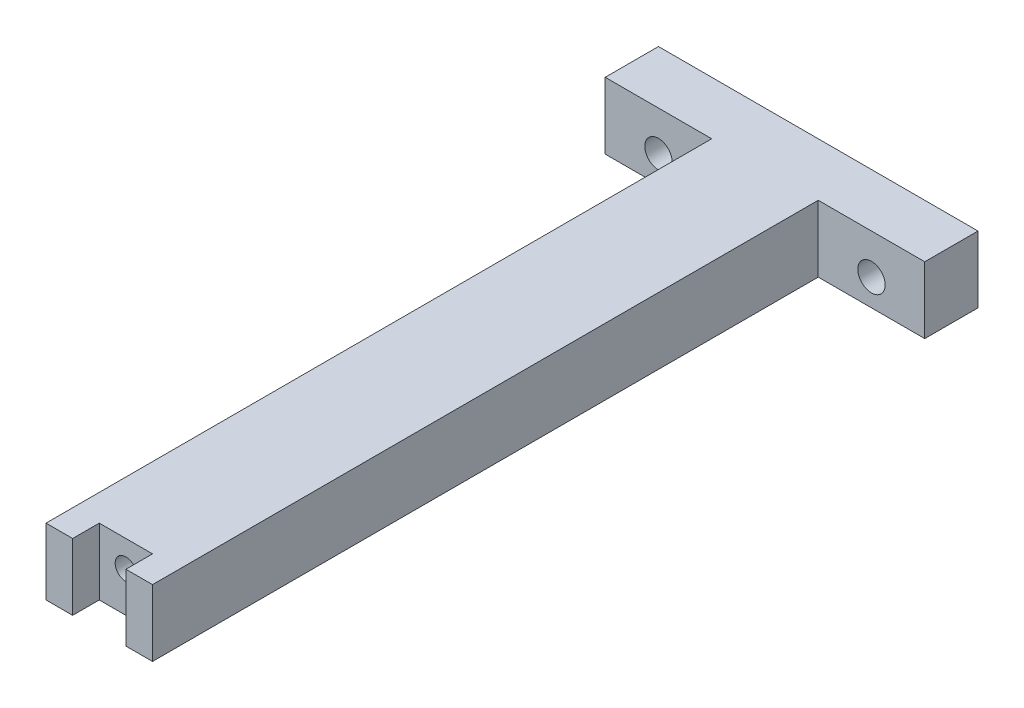
from build123d import *

# Parameters (mm, degrees)
SKETCH1_W                   = 76.2
SKETCH1_H                   = 15.875
BOSS_EXTRUDE1_DEPTH         = 171.45
SKETCH2_W                   = 25.4
SKETCH2_H                   = 15.875
CUT_EXTRUDE1_DEPTH          = 158.75
SKETCH3_W                   = 12.7
SKETCH3_H                   = 15.875
CUT_EXTRUDE2_DEPTH          = 6.35
F_1_4_20_TAPPED_HOLE1_D     = 5.1054
F_1_4_20_TAPPED_HOLE1_DEPTH = 10.8204
F_1_4_20_TAPPED_HOLE1_TIP   = 1.533816902
SKETCH6_R                   = 3.2639
CUT_EXTRUDE3_DEPTH          = 159.75
CUT_EXTRUDE3_DEPTH_BACK     = 13.7


with BuildPart() as part:
    # Sketch1 → Boss-Extrude1 (new body)
    with BuildSketch(Plane.XY):
        Rectangle(SKETCH1_W, SKETCH1_H)
    extrude(amount=BOSS_EXTRUDE1_DEPTH)

    # Sketch2 → Cut-Extrude1 (cut)
    with BuildSketch(Plane.XY.offset(171.45)):
        with Locations((-25.4, 0)):
            Rectangle(SKETCH2_W, SKETCH2_H)
        with Locations((25.4, 0)):
            Rectangle(SKETCH2_W, SKETCH2_H)
    extrude(amount=-CUT_EXTRUDE1_DEPTH, mode=Mode.SUBTRACT)

    # Sketch3 → Cut-Extrude2 (cut)
    with BuildSketch(Plane.XY.offset(171.45)):
        Rectangle(SKETCH3_W, SKETCH3_H)
    extrude(amount=-CUT_EXTRUDE2_DEPTH, mode=Mode.SUBTRACT)

    # 1/4-20 Tapped Hole1
    with Locations(Plane.XY.offset(165.1)):
        with Locations((0, 1.5875)):
            Hole(F_1_4_20_TAPPED_HOLE1_D / 2, depth=F_1_4_20_TAPPED_HOLE1_DEPTH)
            with Locations((0, 0, -(F_1_4_20_TAPPED_HOLE1_DEPTH + F_1_4_20_TAPPED_HOLE1_TIP / 2))):  # 118° drill point
                Cone(0, F_1_4_20_TAPPED_HOLE1_D / 2, F_1_4_20_TAPPED_HOLE1_TIP, mode=Mode.SUBTRACT)

    # Sketch6 → Cut-Extrude3 (cut, two sides)
    with BuildSketch(Plane.XY.offset(12.7)) as cut_extrude3_sk:
        with Locations((-25.4, -1.5875)):
            Circle(SKETCH6_R)
        with Locations((25.4, -1.5875)):
            Circle(SKETCH6_R)
    extrude(amount=CUT_EXTRUDE3_DEPTH, mode=Mode.SUBTRACT)
    extrude(cut_extrude3_sk.sketch, amount=-CUT_EXTRUDE3_DEPTH_BACK, mode=Mode.SUBTRACT)


solid = part.part
